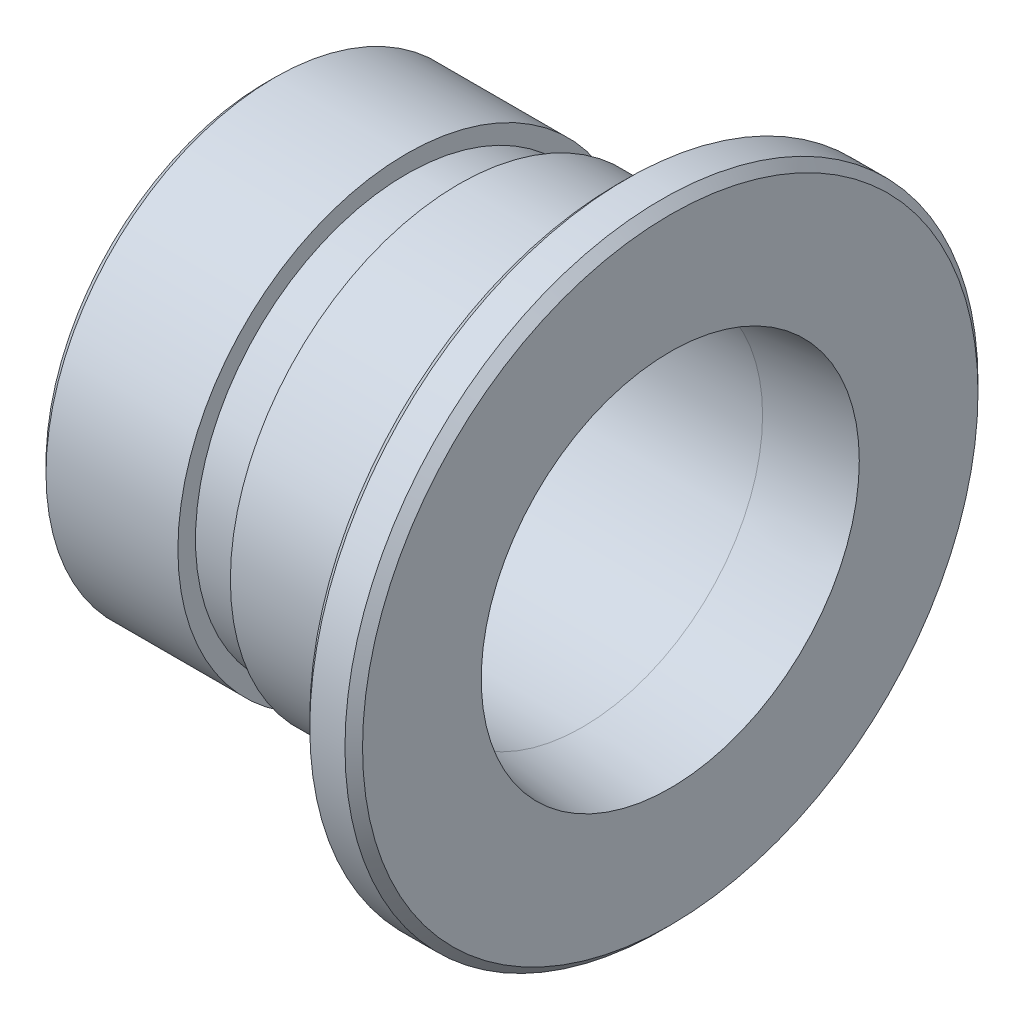
from build123d import *


with BuildPart() as part:
    # Esquisse1 → Révolution1 (revolve)
    with BuildSketch(Plane.XY, mode=Mode.PRIVATE) as r_volution1_sk:
        Polygon((0, 10.75), (0, 17.5), (-0.5, 18), (-2.5, 18), (-3, 17.5), (-3, 13), (-12.015801634, 13), (-11.984198366, 12), (-15, 12), (-15, 13), (-22.5, 13), (-23, 12.5), (-23, 10.75), (-18, 10.25), (-5, 10.25), align=None)
    revolve(r_volution1_sk.sketch.rotate(Axis((0, 0, 0), (-1, 0, 0)), 90), axis=Axis((0, 0, 0), (-1, 0, 0)))  # turned: the seam where the file's is


solid = part.part
